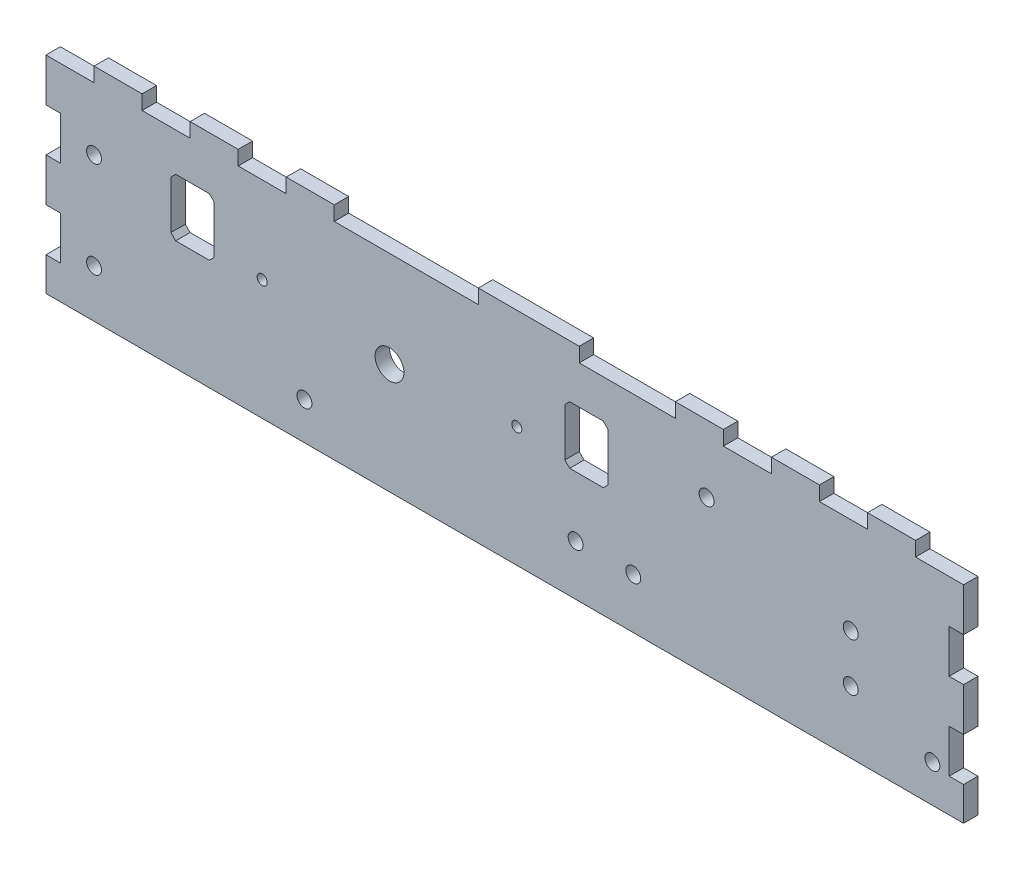
from build123d import *

# Parameters (mm, degrees)
SKETCH1_W           = 191
SKETCH1_H           = 46
SKETCH1_R           = 1.549999948
BOSS_EXTRUDE1_DEPTH = 3
CUT_EXTRUDE1_REACH  = 198.484
SKETCH3_W           = 10
SKETCH3_H           = 3
SKETCH3_W_2         = 30
SKETCH3_W_3         = 20
CUT_EXTRUDE2_REACH  = 198.484
SKETCH4_W           = 3
SKETCH4_H           = 9
CUT_EXTRUDE3_REACH  = 198.484
SKETCH6_R           = 3
CUT_EXTRUDE4_REACH  = 198.484
SKETCH7_R           = 1.55
CUT_EXTRUDE5_REACH  = 198.484
SKETCH8_R           = 1.55
CUT_EXTRUDE6_REACH  = 198.484
SKETCH9_R           = 1.05
SKETCH9_W           = 9
SKETCH9_H           = 12
CHAMFER1_SIZE       = 1
CUT_EXTRUDE7_REACH  = 198.484
SKETCH10_R          = 1.05


with BuildPart() as part:
    # Sketch1 → Boss-Extrude1 (new body)
    with BuildSketch(Plane.XY):
        with Locations((-95.5, 23)):
            Rectangle(SKETCH1_W, SKETCH1_H)
        with Locations((-181, 30)):
            Circle(SKETCH1_R, mode=Mode.SUBTRACT)
        with Locations((-181, 10)):
            Circle(SKETCH1_R, mode=Mode.SUBTRACT)
    extrude(amount=BOSS_EXTRUDE1_DEPTH)

    # Sketch3 → Cut-Extrude1 (cut, up to next)
    with BuildSketch(Plane(origin=(0, 0, 0), x_dir=(-1, 0, 0), z_dir=(0, 0, -1)), mode=Mode.PRIVATE) as cut_extrude1_sk1:
        with Locations((45, 44.5)):
            Rectangle(SKETCH3_W, SKETCH3_H)
    cut_extrude1_tool1 = extrude(cut_extrude1_sk1.sketch, amount=-CUT_EXTRUDE1_REACH, mode=Mode.PRIVATE) & part.part
    # Sketch3 → Cut-Extrude1 (cut, up to next)
    with BuildSketch(Plane(origin=(0, 0, 0), x_dir=(-1, 0, 0), z_dir=(0, 0, -1)), mode=Mode.PRIVATE) as cut_extrude1_sk2:
        with Locations((25, 44.5)):
            Rectangle(SKETCH3_W, SKETCH3_H)
    cut_extrude1_tool2 = extrude(cut_extrude1_sk2.sketch, amount=-CUT_EXTRUDE1_REACH, mode=Mode.PRIVATE) & part.part
    # Sketch3 → Cut-Extrude1 (cut, up to next)
    with BuildSketch(Plane(origin=(0, 0, 0), x_dir=(-1, 0, 0), z_dir=(0, 0, -1)), mode=Mode.PRIVATE) as cut_extrude1_sk3:
        with Locations((5, 44.5)):
            Rectangle(SKETCH3_W, SKETCH3_H)
    cut_extrude1_tool3 = extrude(cut_extrude1_sk3.sketch, amount=-CUT_EXTRUDE1_REACH, mode=Mode.PRIVATE) & part.part
    # Sketch3 → Cut-Extrude1 (cut, up to next)
    with BuildSketch(Plane(origin=(0, 0, 0), x_dir=(-1, 0, 0), z_dir=(0, 0, -1)), mode=Mode.PRIVATE) as cut_extrude1_sk4:
        with Locations((166, 44.5)):
            Rectangle(SKETCH3_W, SKETCH3_H)
    cut_extrude1_tool4 = extrude(cut_extrude1_sk4.sketch, amount=-CUT_EXTRUDE1_REACH, mode=Mode.PRIVATE) & part.part
    # Sketch3 → Cut-Extrude1 (cut, up to next)
    with BuildSketch(Plane(origin=(0, 0, 0), x_dir=(-1, 0, 0), z_dir=(0, 0, -1)), mode=Mode.PRIVATE) as cut_extrude1_sk5:
        with Locations((146, 44.5)):
            Rectangle(SKETCH3_W, SKETCH3_H)
    cut_extrude1_tool5 = extrude(cut_extrude1_sk5.sketch, amount=-CUT_EXTRUDE1_REACH, mode=Mode.PRIVATE) & part.part
    # Sketch3 → Cut-Extrude1 (cut, up to next)
    with BuildSketch(Plane(origin=(0, 0, 0), x_dir=(-1, 0, 0), z_dir=(0, 0, -1)), mode=Mode.PRIVATE) as cut_extrude1_sk6:
        with Locations((116, 44.5)):
            Rectangle(SKETCH3_W_2, SKETCH3_H)
    cut_extrude1_tool6 = extrude(cut_extrude1_sk6.sketch, amount=-CUT_EXTRUDE1_REACH, mode=Mode.PRIVATE) & part.part
    # Sketch3 → Cut-Extrude1 (cut, up to next)
    with BuildSketch(Plane(origin=(0, 0, 0), x_dir=(-1, 0, 0), z_dir=(0, 0, -1)), mode=Mode.PRIVATE) as cut_extrude1_sk7:
        with Locations((70, 44.5)):
            Rectangle(SKETCH3_W_3, SKETCH3_H)
    cut_extrude1_tool7 = extrude(cut_extrude1_sk7.sketch, amount=-CUT_EXTRUDE1_REACH, mode=Mode.PRIVATE) & part.part
    # Sketch3 → Cut-Extrude1 (cut, up to next)
    with BuildSketch(Plane(origin=(0, 0, 0), x_dir=(-1, 0, 0), z_dir=(0, 0, -1)), mode=Mode.PRIVATE) as cut_extrude1_sk8:
        with Locations((186, 44.5)):
            Rectangle(SKETCH3_W, SKETCH3_H)
    cut_extrude1_tool8 = extrude(cut_extrude1_sk8.sketch, amount=-CUT_EXTRUDE1_REACH, mode=Mode.PRIVATE) & part.part
    add(cut_extrude1_tool1.solids().sort_by_distance((-45, 44.5, 0))[0], mode=Mode.SUBTRACT)
    add(cut_extrude1_tool2.solids().sort_by_distance((-25, 44.5, 0))[0], mode=Mode.SUBTRACT)
    add(cut_extrude1_tool3.solids().sort_by_distance((-5, 44.5, 0))[0], mode=Mode.SUBTRACT)
    add(cut_extrude1_tool4.solids().sort_by_distance((-166, 44.5, 0))[0], mode=Mode.SUBTRACT)
    add(cut_extrude1_tool5.solids().sort_by_distance((-146, 44.5, 0))[0], mode=Mode.SUBTRACT)
    add(cut_extrude1_tool6.solids().sort_by_distance((-116, 44.5, 0))[0], mode=Mode.SUBTRACT)
    add(cut_extrude1_tool7.solids().sort_by_distance((-70, 44.5, 0))[0], mode=Mode.SUBTRACT)
    add(cut_extrude1_tool8.solids().sort_by_distance((-186, 44.5, 0))[0], mode=Mode.SUBTRACT)

    # Sketch4 → Cut-Extrude2 (cut, up to next)
    with BuildSketch(Plane.XY.offset(3), mode=Mode.PRIVATE) as cut_extrude2_sk1:
        with Locations((-1.5, 29.5)):
            Rectangle(SKETCH4_W, SKETCH4_H)
    cut_extrude2_tool1 = extrude(cut_extrude2_sk1.sketch, amount=-CUT_EXTRUDE2_REACH, mode=Mode.PRIVATE) & part.part
    # Sketch4 → Cut-Extrude2 (cut, up to next)
    with BuildSketch(Plane.XY.offset(3), mode=Mode.PRIVATE) as cut_extrude2_sk2:
        with Locations((-1.5, 11.5)):
            Rectangle(SKETCH4_W, SKETCH4_H)
    cut_extrude2_tool2 = extrude(cut_extrude2_sk2.sketch, amount=-CUT_EXTRUDE2_REACH, mode=Mode.PRIVATE) & part.part
    cut_extrude2_1 = cut_extrude2_tool1.solids().sort_by_distance((-1.5, 29.5, 3))[0]
    add(cut_extrude2_1, mode=Mode.SUBTRACT)
    cut_extrude2_2 = cut_extrude2_tool2.solids().sort_by_distance((-1.5, 11.5, 3))[0]
    add(cut_extrude2_2, mode=Mode.SUBTRACT)
    cut_extrude2 = cut_extrude2_1 + cut_extrude2_2  # Cut-Extrude2 as one shape, for the pattern or mirror that repeats it

    # Mirror1: Cut-Extrude2 across plane
    add(cut_extrude2.mirror(Plane(origin=(-95.5, 0, 0), x_dir=(0, 0, 1), z_dir=(1, 0, 0))), mode=Mode.SUBTRACT)

    # Sketch6 → Cut-Extrude3 (cut, up to next)
    with BuildSketch(Plane.XY.offset(3), mode=Mode.PRIVATE) as cut_extrude3_sk1:
        with Locations((-119.5, 23)):
            Circle(SKETCH6_R)
    cut_extrude3_tool1 = extrude(cut_extrude3_sk1.sketch, amount=-CUT_EXTRUDE3_REACH, mode=Mode.PRIVATE) & part.part
    add(cut_extrude3_tool1.solids().sort_by_distance((-119.5, 23, 3))[0], mode=Mode.SUBTRACT)

    # Sketch7 → Cut-Extrude4 (cut, up to next)
    with BuildSketch(Plane.XY.offset(3), mode=Mode.PRIVATE) as cut_extrude4_sk1:
        with Locations((-53.5, 32)):
            Circle(SKETCH7_R)
    cut_extrude4_tool1 = extrude(cut_extrude4_sk1.sketch, amount=-CUT_EXTRUDE4_REACH, mode=Mode.PRIVATE) & part.part
    # Sketch7 → Cut-Extrude4 (cut, up to next)
    with BuildSketch(Plane.XY.offset(3), mode=Mode.PRIVATE) as cut_extrude4_sk2:
        with Locations((-68.757359313, 10.5)):
            Circle(SKETCH7_R)
    cut_extrude4_tool2 = extrude(cut_extrude4_sk2.sketch, amount=-CUT_EXTRUDE4_REACH, mode=Mode.PRIVATE) & part.part
    # Sketch7 → Cut-Extrude4 (cut, up to next)
    with BuildSketch(Plane.XY.offset(3), mode=Mode.PRIVATE) as cut_extrude4_sk3:
        with Locations((-80.757359313, 10.5)):
            Circle(SKETCH7_R)
    cut_extrude4_tool3 = extrude(cut_extrude4_sk3.sketch, amount=-CUT_EXTRUDE4_REACH, mode=Mode.PRIVATE) & part.part
    # Sketch7 → Cut-Extrude4 (cut, up to next)
    with BuildSketch(Plane.XY.offset(3), mode=Mode.PRIVATE) as cut_extrude4_sk4:
        with Locations((-23.5, 23)):
            Circle(SKETCH7_R)
    cut_extrude4_tool4 = extrude(cut_extrude4_sk4.sketch, amount=-CUT_EXTRUDE4_REACH, mode=Mode.PRIVATE) & part.part
    # Sketch7 → Cut-Extrude4 (cut, up to next)
    with BuildSketch(Plane.XY.offset(3), mode=Mode.PRIVATE) as cut_extrude4_sk5:
        with Locations((-23.5, 13)):
            Circle(SKETCH7_R)
    cut_extrude4_tool5 = extrude(cut_extrude4_sk5.sketch, amount=-CUT_EXTRUDE4_REACH, mode=Mode.PRIVATE) & part.part
    add(cut_extrude4_tool1.solids().sort_by_distance((-53.5, 32, 3))[0], mode=Mode.SUBTRACT)
    add(cut_extrude4_tool2.solids().sort_by_distance((-68.757359, 10.5, 3))[0], mode=Mode.SUBTRACT)
    add(cut_extrude4_tool3.solids().sort_by_distance((-80.757359, 10.5, 3))[0], mode=Mode.SUBTRACT)
    add(cut_extrude4_tool4.solids().sort_by_distance((-23.5, 23, 3))[0], mode=Mode.SUBTRACT)
    add(cut_extrude4_tool5.solids().sort_by_distance((-23.5, 13, 3))[0], mode=Mode.SUBTRACT)

    # Sketch8 → Cut-Extrude5 (cut, up to next)
    with BuildSketch(Plane(origin=(0, 0, 0), x_dir=(-1, 0, 0), z_dir=(0, 0, -1)), mode=Mode.PRIVATE) as cut_extrude5_sk1:
        with Locations((137.2, 7.8)):
            Circle(SKETCH8_R)
    cut_extrude5_tool1 = extrude(cut_extrude5_sk1.sketch, amount=-CUT_EXTRUDE5_REACH, mode=Mode.PRIVATE) & part.part
    # Sketch8 → Cut-Extrude5 (cut, up to next)
    with BuildSketch(Plane(origin=(0, 0, 0), x_dir=(-1, 0, 0), z_dir=(0, 0, -1)), mode=Mode.PRIVATE) as cut_extrude5_sk2:
        with Locations((6.5, 7.8)):
            Circle(SKETCH8_R)
    cut_extrude5_tool2 = extrude(cut_extrude5_sk2.sketch, amount=-CUT_EXTRUDE5_REACH, mode=Mode.PRIVATE) & part.part
    add(cut_extrude5_tool1.solids().sort_by_distance((-137.2, 7.8, 0))[0], mode=Mode.SUBTRACT)
    add(cut_extrude5_tool2.solids().sort_by_distance((-6.5, 7.8, 0))[0], mode=Mode.SUBTRACT)

    # Sketch9 → Cut-Extrude6 (cut, up to next)
    with BuildSketch(Plane.XY.offset(3), mode=Mode.PRIVATE) as cut_extrude6_sk1:
        with Locations((-93, 25)):
            Circle(SKETCH9_R)
    cut_extrude6_tool1 = extrude(cut_extrude6_sk1.sketch, amount=-CUT_EXTRUDE6_REACH, mode=Mode.PRIVATE) & part.part
    # Sketch9 → Cut-Extrude6 (cut, up to next)
    with BuildSketch(Plane.XY.offset(3), mode=Mode.PRIVATE) as cut_extrude6_sk2:
        with Locations((-78.5, 29)):
            Rectangle(SKETCH9_W, SKETCH9_H)
    cut_extrude6_tool2 = extrude(cut_extrude6_sk2.sketch, amount=-CUT_EXTRUDE6_REACH, mode=Mode.PRIVATE) & part.part
    add(cut_extrude6_tool1.solids().sort_by_distance((-93, 25, 3))[0], mode=Mode.SUBTRACT)
    add(cut_extrude6_tool2.solids().sort_by_distance((-78.5, 29, 3))[0], mode=Mode.SUBTRACT)

    # Chamfer1
    chamfer1_edges = [part.edges().sort_by_distance(p)[0] for p in [
        (-83, 35, 1.5),
        (-83, 23, 1.5),
        (-74, 23, 1.5),
        (-74, 35, 1.5),
    ]]
    chamfer(chamfer1_edges, length=CHAMFER1_SIZE)

    # Sketch10 → Cut-Extrude7 (cut, up to next)
    with BuildSketch(Plane.XY.offset(3), mode=Mode.PRIVATE) as cut_extrude7_sk1:
        Polygon((-165, 34), (-165, 24), (-164, 23), (-157, 23), (-156, 24), (-156, 34), (-157, 35), (-164, 35), align=None)
    cut_extrude7_tool1 = extrude(cut_extrude7_sk1.sketch, amount=-CUT_EXTRUDE7_REACH, mode=Mode.PRIVATE) & part.part
    # Sketch10 → Cut-Extrude7 (cut, up to next)
    with BuildSketch(Plane.XY.offset(3), mode=Mode.PRIVATE) as cut_extrude7_sk2:
        with Locations((-146, 25)):
            Circle(SKETCH10_R)
    cut_extrude7_tool2 = extrude(cut_extrude7_sk2.sketch, amount=-CUT_EXTRUDE7_REACH, mode=Mode.PRIVATE) & part.part
    add(cut_extrude7_tool1.solids().sort_by_distance((-160.5, 29, 3))[0], mode=Mode.SUBTRACT)
    add(cut_extrude7_tool2.solids().sort_by_distance((-146, 25, 3))[0], mode=Mode.SUBTRACT)


solid = part.part
